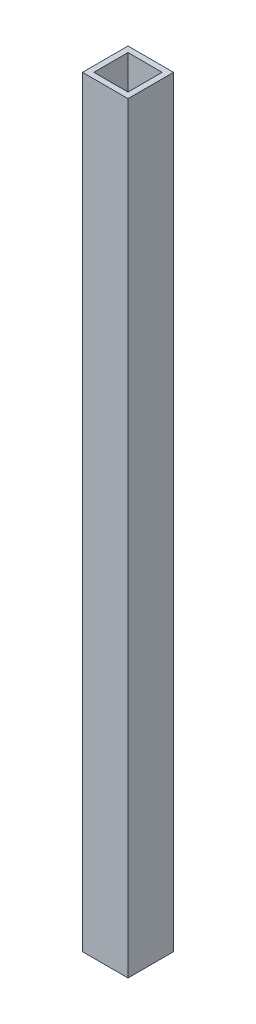
from build123d import *

# Parameters (mm, degrees)
SKETCH1_W           = 25.4
SKETCH1_H           = 25.4
SKETCH1_W_2         = 19.05
SKETCH1_H_2         = 19.05
BOSS_EXTRUDE1_DEPTH = 424.434


with BuildPart() as part:
    # Sketch1 → Boss-Extrude1 (new body)
    with BuildSketch(Plane(origin=(0, 0, 0), x_dir=(1, 0, 0), z_dir=(0, 1, 0))):
        Rectangle(SKETCH1_W, SKETCH1_H)
        Rectangle(SKETCH1_W_2, SKETCH1_H_2, mode=Mode.SUBTRACT)
    extrude(amount=BOSS_EXTRUDE1_DEPTH)


solid = part.part
